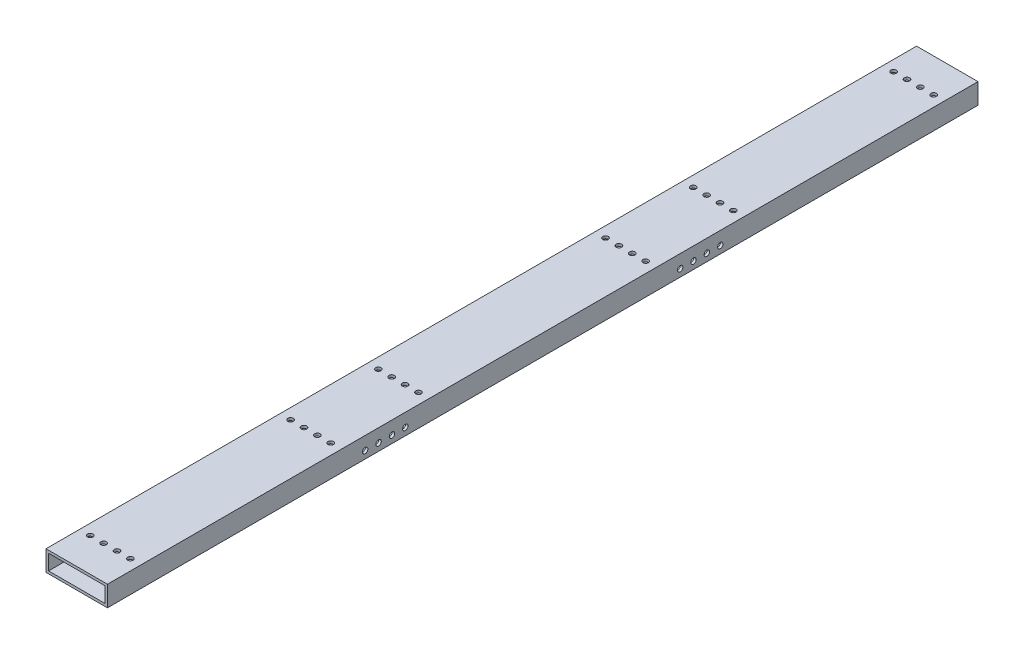
from build123d import *

# Parameters (mm, degrees)
SKETCH1_W           = 76.2
SKETCH1_H           = 25.4
SKETCH1_W_2         = 69.85
SKETCH1_H_2         = 19.05
BOSS_EXTRUDE1_DEPTH = 1079.5
SKETCH2_R           = 3.3782
CUT_EXTRUDE1_DEPTH  = 26.4
SKETCH3_R           = 3.3782
CUT_EXTRUDE2_DEPTH  = 26.4
SKETCH4_R           = 3.3782
CUT_EXTRUDE3_DEPTH  = 77.2


with BuildPart() as part:
    # Sketch1 → Boss-Extrude1 (new body)
    with BuildSketch(Plane.XY):
        with Locations((38.1, 12.7)):
            Rectangle(SKETCH1_W, SKETCH1_H)
        with Locations((38.1, 12.7)):
            Rectangle(SKETCH1_W_2, SKETCH1_H_2, mode=Mode.SUBTRACT)
    extrude(amount=BOSS_EXTRUDE1_DEPTH)

    # Sketch2 → Cut-Extrude1 (cut, through all)
    with BuildSketch(Plane.XZ):
        with Locations((13.21308, 41.6687)):
            Circle(SKETCH2_R)
        with Locations((29.80436, 41.6687)):
            Circle(SKETCH2_R)
        with Locations((46.39564, 41.6687)):
            Circle(SKETCH2_R)
        with Locations((62.98692, 41.6687)):
            Circle(SKETCH2_R)
    cut_extrude1 = extrude(amount=-CUT_EXTRUDE1_DEPTH, mode=Mode.SUBTRACT)

    # Mirror1: Cut-Extrude1 across plane
    add(cut_extrude1.mirror(Plane(origin=(0, 0, 539.75), x_dir=(1, 0, 0), z_dir=(0, 0, -1))), mode=Mode.SUBTRACT)

    # Sketch3 → Cut-Extrude2 (cut, through all)
    with BuildSketch(Plane(origin=(0, 25.4, 0), x_dir=(1, 0, 0), z_dir=(0, 1, 0))):
        with Locations((13.21308, -789.3812)):
            Circle(SKETCH3_R)
        with Locations((29.80436, -789.3812)):
            Circle(SKETCH3_R)
        with Locations((46.39564, -789.3812)):
            Circle(SKETCH3_R)
        with Locations((62.98692, -789.3812)):
            Circle(SKETCH3_R)
        with Locations((29.80436, -680.6438)):
            Circle(SKETCH3_R)
        with Locations((46.39564, -680.6438)):
            Circle(SKETCH3_R)
        with Locations((62.98692, -680.6438)):
            Circle(SKETCH3_R)
        with Locations((13.21308, -290.1188)):
            Circle(SKETCH3_R)
        with Locations((29.80436, -290.1188)):
            Circle(SKETCH3_R)
        with Locations((46.39564, -290.1188)):
            Circle(SKETCH3_R)
        with Locations((62.98692, -290.1188)):
            Circle(SKETCH3_R)
        with Locations((13.21308, -398.8562)):
            Circle(SKETCH3_R)
        with Locations((29.80436, -398.8562)):
            Circle(SKETCH3_R)
        with Locations((46.39564, -398.8562)):
            Circle(SKETCH3_R)
        with Locations((62.98692, -398.8562)):
            Circle(SKETCH3_R)
        with Locations((13.21308, -680.6438)):
            Circle(SKETCH3_R)
    extrude(amount=-CUT_EXTRUDE2_DEPTH, mode=Mode.SUBTRACT)

    # Sketch4 → Cut-Extrude3 (cut, through all)
    with BuildSketch(Plane.ZY):
        with Locations((710.12558, 9.1313)):
            Circle(SKETCH4_R)
        with Locations((759.89942, 9.1313)):
            Circle(SKETCH4_R)
        with Locations((743.30814, 9.1313)):
            Circle(SKETCH4_R)
        with Locations((726.71686, 9.1313)):
            Circle(SKETCH4_R)
    cut_extrude3 = extrude(amount=-CUT_EXTRUDE3_DEPTH, mode=Mode.SUBTRACT)

    # Mirror2: Cut-Extrude3 across plane
    add(cut_extrude3.mirror(Plane(origin=(0, 0, 539.75), x_dir=(1, 0, 0), z_dir=(0, 0, -1))), mode=Mode.SUBTRACT)


solid = part.part
